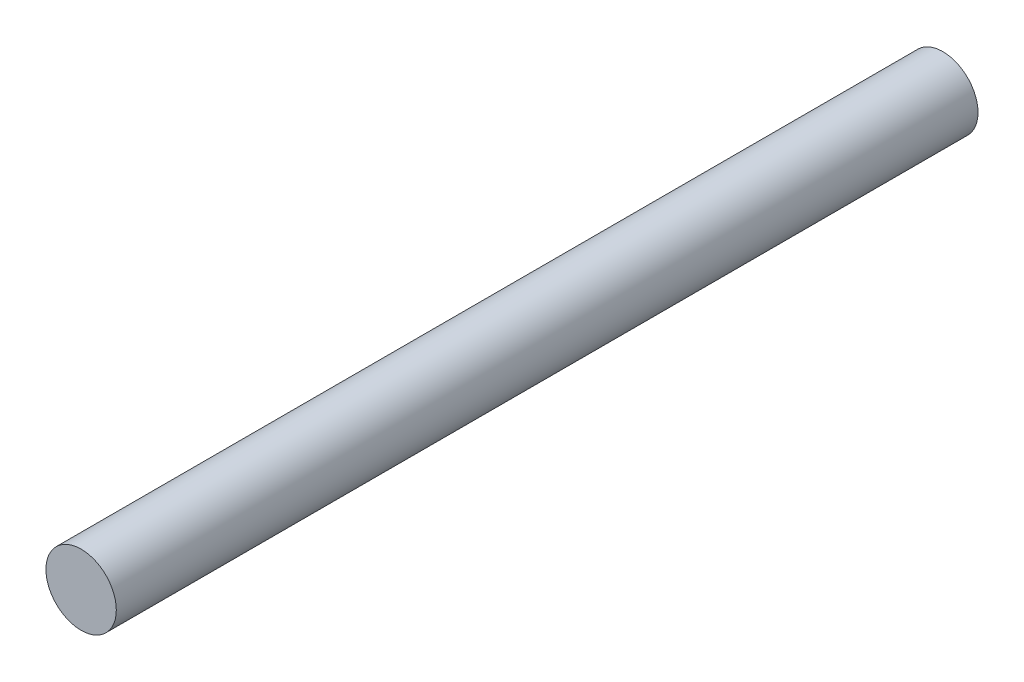
from build123d import *

# Parameters (mm, degrees)
SKETCH1_R           = 2.45
BOSS_EXTRUDE1_DEPTH = 60


with BuildPart() as part:
    # Sketch1 → Boss-Extrude1 (new body)
    with BuildSketch(Plane.XY):
        Circle(SKETCH1_R)
    extrude(amount=BOSS_EXTRUDE1_DEPTH)


solid = part.part
